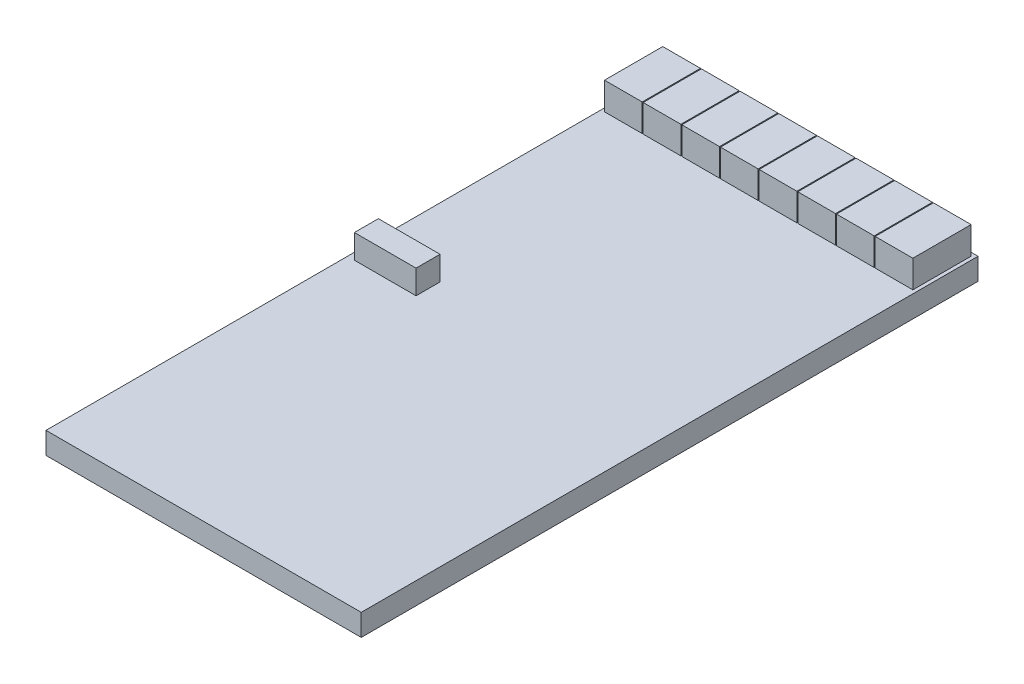
from build123d import *

# Parameters (mm, degrees)
SKETCH1_W           = 23
SKETCH1_H           = 45
BOSS_EXTRUDE1_DEPTH = 1.5875
SKETCH2_W           = 16.5
SKETCH2_H           = 16.5
BOSS_EXTRUDE2_DEPTH = 1.14
BOSS_EXTRUDE2_TAPER = 42.37
SKETCH3_W           = 14.42
SKETCH3_H           = 14.42
BOSS_EXTRUDE3_DEPTH = 0.26
SKETCH4_W           = 2.75
SKETCH4_H           = 4.25
BOSS_EXTRUDE4_DEPTH = 2
SKETCH5_W           = 4.5
SKETCH5_H           = 1.75
BOSS_EXTRUDE5_DEPTH = 1.75


with BuildPart() as part:
    # Sketch1 → Boss-Extrude1 (new body)
    with BuildSketch(Plane(origin=(0, 0, 0), x_dir=(1, 0, 0), z_dir=(0, 1, 0))):
        with Locations((11.5, 22.5)):
            Rectangle(SKETCH1_W, SKETCH1_H)
    extrude(amount=BOSS_EXTRUDE1_DEPTH)

    # Sketch2 → Boss-Extrude2 (add)
    with BuildSketch(Plane.XZ):
        with Locations((11.5, -16.5)):
            Rectangle(SKETCH2_W, SKETCH2_H)
    extrude(amount=BOSS_EXTRUDE2_DEPTH, taper=BOSS_EXTRUDE2_TAPER)

    # Sketch3 → Boss-Extrude3 (add)
    with BuildSketch(Plane.XZ.offset(1.14)):
        with Locations((11.5, -16.5)):
            Rectangle(SKETCH3_W, SKETCH3_H)
    extrude(amount=BOSS_EXTRUDE3_DEPTH)

    # Sketch4 → Boss-Extrude4 (add)
    with BuildSketch(Plane(origin=(0, 1.5875, 0), x_dir=(1, 0, 0), z_dir=(0, 1, 0))):
        with Locations((4.446, 42.625)):
            Rectangle(SKETCH4_W, SKETCH4_H)
        with Locations((1.625, 42.625)):
            Rectangle(SKETCH4_W, SKETCH4_H)
        with Locations((7.267, 42.625)):
            Rectangle(SKETCH4_W, SKETCH4_H)
        with Locations((10.088, 42.625)):
            Rectangle(SKETCH4_W, SKETCH4_H)
        with Locations((12.909, 42.625)):
            Rectangle(SKETCH4_W, SKETCH4_H)
        with Locations((15.73, 42.625)):
            Rectangle(SKETCH4_W, SKETCH4_H)
        with Locations((18.551, 42.625)):
            Rectangle(SKETCH4_W, SKETCH4_H)
        with Locations((21.372, 42.625)):
            Rectangle(SKETCH4_W, SKETCH4_H)
    extrude(amount=BOSS_EXTRUDE4_DEPTH)

    # Sketch5 → Boss-Extrude5 (add)
    with BuildSketch(Plane(origin=(0, 1.5875, 0), x_dir=(1, 0, 0), z_dir=(0, 1, 0))):
        with Locations((2.75, 22.875)):
            Rectangle(SKETCH5_W, SKETCH5_H)
    extrude(amount=BOSS_EXTRUDE5_DEPTH)


solid = part.part
